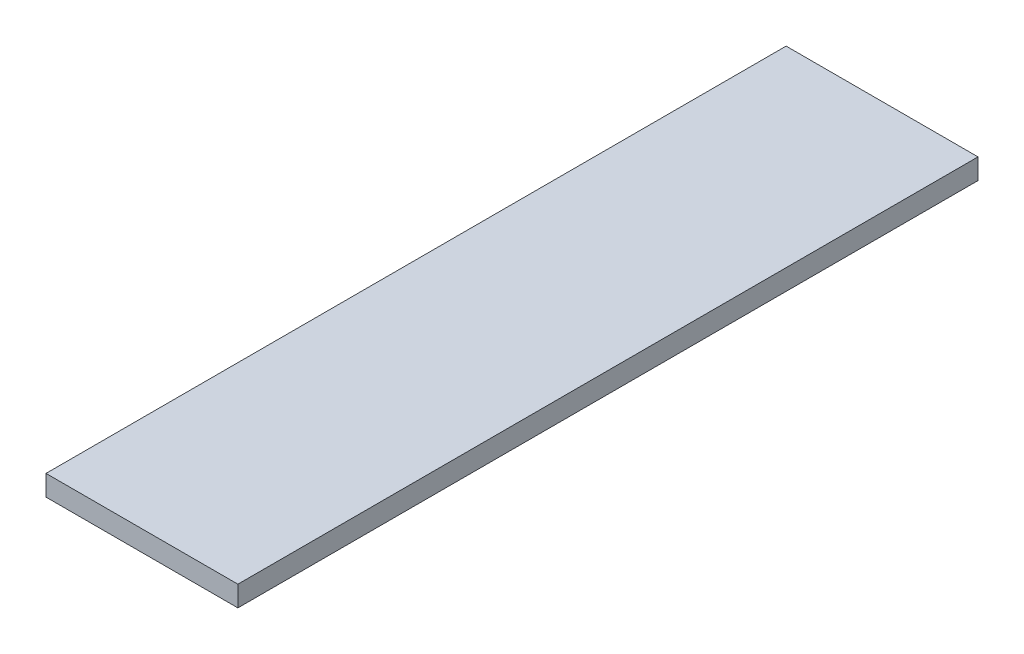
from build123d import *

# Parameters (mm, degrees)
SKETCH1_W           = 177.8
SKETCH1_H           = 685.8
BOSS_EXTRUDE1_DEPTH = 19.05


with BuildPart() as part:
    # Sketch1 → Boss-Extrude1 (new body)
    with BuildSketch(Plane(origin=(0, 0, 0), x_dir=(1, 0, 0), z_dir=(0, 1, 0))):
        Rectangle(SKETCH1_W, SKETCH1_H)
    extrude(amount=BOSS_EXTRUDE1_DEPTH)


solid = part.part
